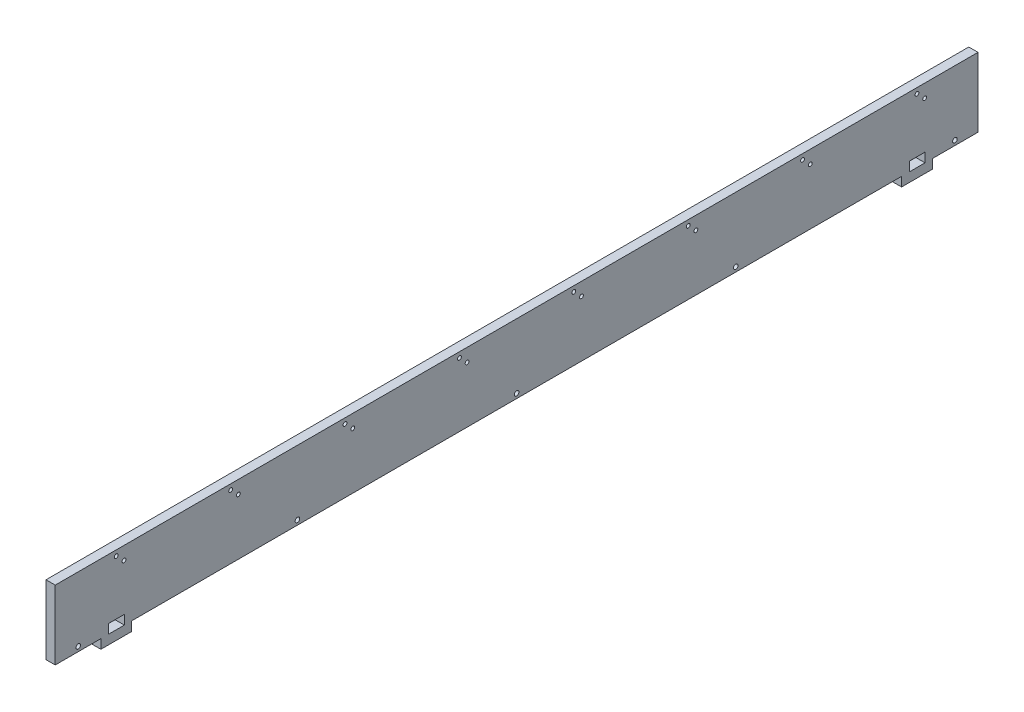
from build123d import *

# Parameters (mm, degrees)
SKETCH1_W           = 1220
SKETCH1_H           = 102
BOSS_EXTRUDE1_DEPTH = 12
SKETCH4_W           = 84.308730764
SKETCH4_H           = 36.280116476
SKETCH4_W_2         = 1001.25
SKETCH4_H_2         = 42.963295827
SKETCH4_W_3         = 112.735688249
CUT_EXTRUDE1_DEPTH  = 20
SKETCH5_W           = 107.106738726
SKETCH5_H           = 164.152719134
SKETCH5_W_2         = 109.43514609
SKETCH5_H_2         = 176.958959634
CUT_EXTRUDE2_DEPTH  = 20
SKETCH6_R           = 2.5
CUT_EXTRUDE3_DEPTH  = 20
SKETCH7_R           = 2.5
CUT_EXTRUDE4_DEPTH  = 22
SKETCH8_W           = 20.5
SKETCH8_H           = 12.1
CUT_EXTRUDE5_DEPTH  = 20
SKETCH9_R           = 3
CUT_EXTRUDE6_DEPTH  = 20


with BuildPart() as part:
    # Sketch1 → Boss-Extrude1 (new body)
    with BuildSketch(Plane(origin=(0, 0, 0), x_dir=(0, 0, -1), z_dir=(1, 0, 0))):
        with Locations((610, 51)):
            Rectangle(SKETCH1_W, SKETCH1_H)
    extrude(amount=BOSS_EXTRUDE1_DEPTH)

    # Sketch4 → Cut-Extrude1 (cut)
    with BuildSketch(Plane(origin=(12, 0, 0), x_dir=(0, 0, -1), z_dir=(1, 0, 0))):
        with Locations((27.220634618, -6.140058238)):
            Rectangle(SKETCH4_W, SKETCH4_H)
        with Locations((610, -9.481647914)):
            Rectangle(SKETCH4_W_2, SKETCH4_H_2)
        with Locations((1206.992844125, -9.481647914)):
            Rectangle(SKETCH4_W_3, SKETCH4_H_2)
    extrude(amount=-CUT_EXTRUDE1_DEPTH, mode=Mode.SUBTRACT)

    # Sketch5 → Cut-Extrude2 (cut)
    with BuildSketch(Plane(origin=(12, 0, 0), x_dir=(0, 0, -1), z_dir=(1, 0, 0))):
        with Locations((1263.553369363, 24.432676068)):
            Rectangle(SKETCH5_W, SKETCH5_H)
        with Locations((-44.717573045, 30.835796318)):
            Rectangle(SKETCH5_W_2, SKETCH5_H_2)
    extrude(amount=-CUT_EXTRUDE2_DEPTH, mode=Mode.SUBTRACT)

    # Sketch6 → Cut-Extrude3 (cut)
    with BuildSketch(Plane(origin=(12, 0, 0), x_dir=(0, 0, -1), z_dir=(1, 0, 0))):
        with Locations((89.375, 95)):
            Circle(SKETCH6_R)
        with Locations((238.125, 95)):
            Circle(SKETCH6_R)
        with Locations((386.875, 95)):
            Circle(SKETCH6_R)
        with Locations((535.625, 95)):
            Circle(SKETCH6_R)
        with Locations((684.375, 95)):
            Circle(SKETCH6_R)
        with Locations((833.125, 95)):
            Circle(SKETCH6_R)
        with Locations((981.875, 95)):
            Circle(SKETCH6_R)
        with Locations((1130.625, 95)):
            Circle(SKETCH6_R)
    extrude(amount=-CUT_EXTRUDE3_DEPTH, mode=Mode.SUBTRACT)

    # Sketch7 → Cut-Extrude4 (cut)
    with BuildSketch(Plane(origin=(12, 0, 0), x_dir=(0, 0, -1), z_dir=(1, 0, 0))):
        with Locations((99.375, 85)):
            Circle(SKETCH7_R)
        with Locations((248.125, 85)):
            Circle(SKETCH7_R)
        with Locations((396.875, 85)):
            Circle(SKETCH7_R)
        with Locations((545.625, 85)):
            Circle(SKETCH7_R)
        with Locations((694.375, 85)):
            Circle(SKETCH7_R)
        with Locations((843.125, 85)):
            Circle(SKETCH7_R)
        with Locations((991.875, 85)):
            Circle(SKETCH7_R)
        with Locations((1140.625, 85)):
            Circle(SKETCH7_R)
    extrude(amount=-CUT_EXTRUDE4_DEPTH, mode=Mode.SUBTRACT)

    # Sketch8 → Cut-Extrude5 (cut)
    with BuildSketch(Plane(origin=(12, 0, 0), x_dir=(0, 0, -1), z_dir=(1, 0, 0))):
        with Locations((89.625, 18.05)):
            Rectangle(SKETCH8_W, SKETCH8_H)
        with Locations((1130.875, 18.05)):
            Rectangle(SKETCH8_W, SKETCH8_H)
    extrude(amount=-CUT_EXTRUDE5_DEPTH, mode=Mode.SUBTRACT)

    # Sketch9 → Cut-Extrude6 (cut)
    with BuildSketch(Plane(origin=(12, 0, 0), x_dir=(0, 0, -1), z_dir=(1, 0, 0))):
        with Locations((40, 18)):
            Circle(SKETCH9_R)
        with Locations((325, 18)):
            Circle(SKETCH9_R)
        with Locations((610, 18)):
            Circle(SKETCH9_R)
        with Locations((895, 18)):
            Circle(SKETCH9_R)
        with Locations((1180, 18)):
            Circle(SKETCH9_R)
    extrude(amount=-CUT_EXTRUDE6_DEPTH, mode=Mode.SUBTRACT)


solid = part.part
